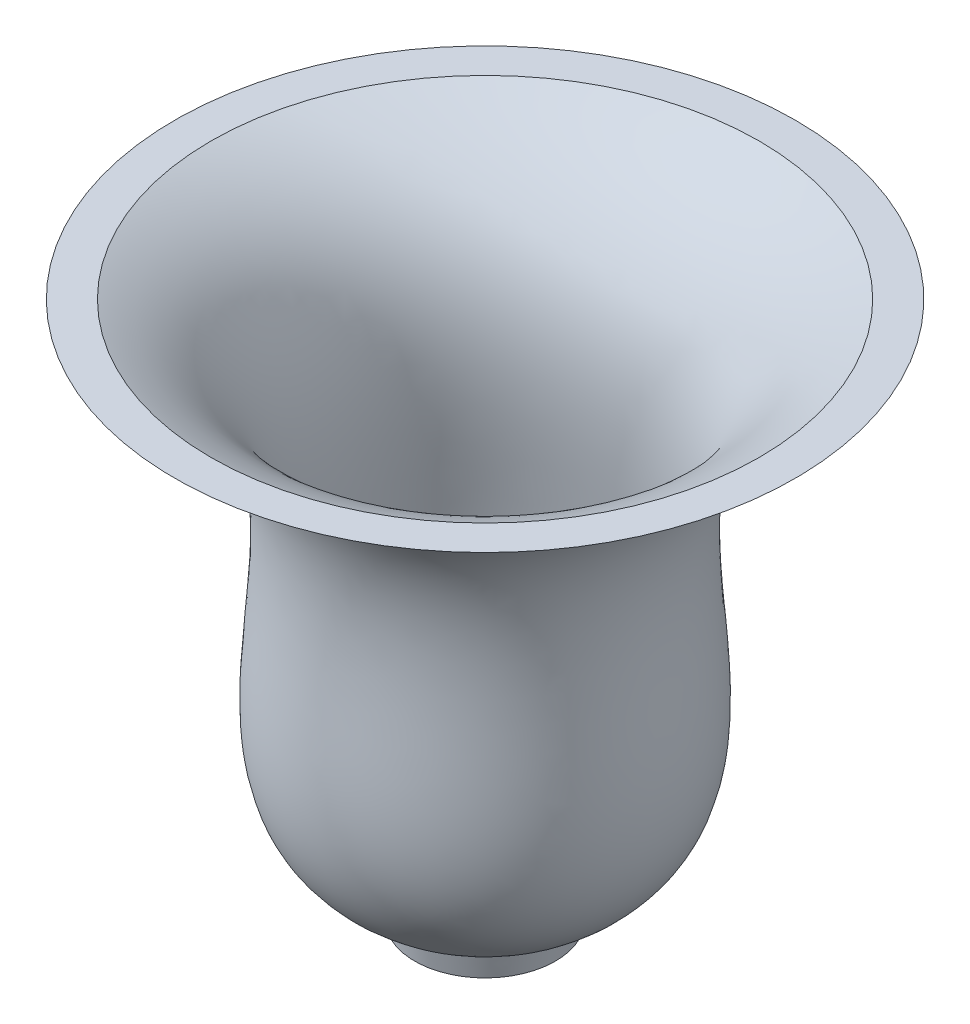
from build123d import *

# Parameters (mm, degrees)
SHELL_2_T           = -1.5
SKETCH_2_R          = 8.468740525
EXTRUDE_1_DEPTH     = 3
EXTRUDE_1_TAPER     = 10
SKETCH_3_R          = 7.124771874
CUT_EXTRUDE_1_DEPTH = 3
CUT_EXTRUDE_1_TAPER = 10


with BuildPart() as part:
    # 草图1 → 旋转1 (revolve)
    with BuildSketch(Plane.XY):
        with BuildLine():
            Line((8.177408078, 37.430202117), (43.148115304, 37.430202117))
            add(Edge.make_bspline(
                [(43.148115304, 37.430202117), (9.519298687, 25.906782304), (42.927889525, -8.546427288), (16.646148603, -20.215366889)],
                knots=[0, 0, 0, 0, 1, 1, 1, 1], degree=3))
            Line((16.646148603, -20.215366889), (8.177408078, -20.215366889))
            Line((8.177408078, -20.215366889), (8.177408078, 37.430202117))
        make_face()
    revolve(axis=Axis((8.177408078, -20.215366889, 0), (0, 1, 0)))

    # 抽壳2
    shell_2_openings = [part.faces().sort_by_distance(p)[0] for p in [
        (8.177408078, 37.430202117, -34.970707226),
    ]]
    offset(amount=SHELL_2_T, openings=shell_2_openings, kind=Kind.INTERSECTION)

    # 草图2 → 凸台-拉伸1 (add)
    with BuildSketch(Plane.XZ.offset(20.215366889)):
        with Locations((8.177408078, 0)):
            Circle(SKETCH_2_R)
    extrude(amount=EXTRUDE_1_DEPTH, taper=EXTRUDE_1_TAPER)

    # 草图3 → 切除-拉伸1 (cut)
    with BuildSketch(Plane.XZ.offset(23.215366889)):
        with Locations((8.177408078, 0)):
            Circle(SKETCH_3_R)
    extrude(amount=-CUT_EXTRUDE_1_DEPTH, taper=CUT_EXTRUDE_1_TAPER, mode=Mode.SUBTRACT)


solid = part.part
